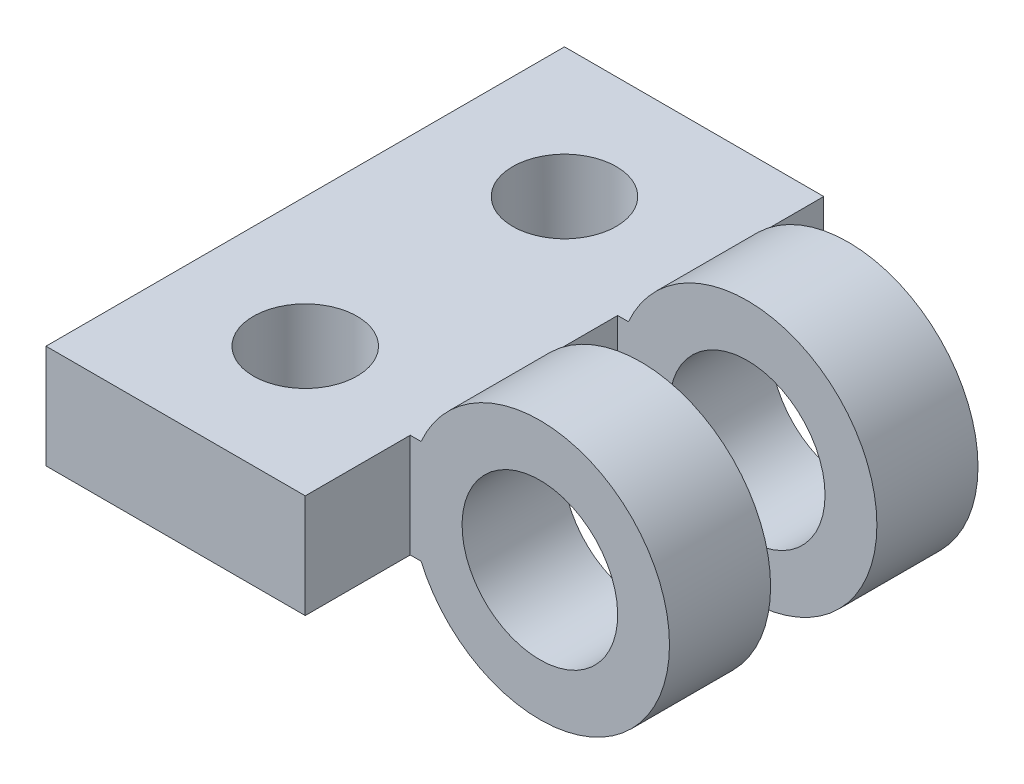
from build123d import *

# Parameters (mm, degrees)
SKETCH2_R                = 2.5
SKETCH2_R_2              = 1.5
BOSS_EXTRUDE1_DEPTH      = 1.95
SKETCH3_W                = 5
SKETCH3_H                = 10
BOSS_EXTRUDE2_DEPTH      = 1
BOSS_EXTRUDE2_DEPTH_BACK = 1
SKETCH5_R                = 2.5
SKETCH5_R_2              = 1.50060411
BOSS_EXTRUDE3_DEPTH      = 0.975
BOSS_EXTRUDE3_DEPTH_BACK = 0.975
SKETCH6_W                = 1.95
SKETCH6_H                = 2
BOSS_EXTRUDE4_DEPTH      = 0.208712
SKETCH7_R                = 1
CUT_EXTRUDE1_DEPTH       = 10


with BuildPart() as part:
    # Sketch2 → Boss-Extrude1 (new body)
    with BuildSketch(Plane.XY):
        Circle(SKETCH2_R)
        Circle(SKETCH2_R_2, mode=Mode.SUBTRACT)
    extrude(amount=BOSS_EXTRUDE1_DEPTH)



with BuildPart() as body_2:
    # Sketch3 → Boss-Extrude2 (new body, two sides)
    with BuildSketch(Plane(origin=(0, 0, 0), x_dir=(1, 0, 0), z_dir=(0, 1, 0))) as boss_extrude2_sk:
        with Locations((-5, -2.975)):
            Rectangle(SKETCH3_W, SKETCH3_H)
    extrude(amount=BOSS_EXTRUDE2_DEPTH)
    extrude(boss_extrude2_sk.sketch, amount=-BOSS_EXTRUDE2_DEPTH_BACK)


with BuildPart() as body_3:
    # Sketch5 → Boss-Extrude3 (new body, two sides)
    with BuildSketch(Plane(origin=(0, 0, 4.975), x_dir=(0, -1, 0), z_dir=(0, 0, 1))) as boss_extrude3_sk:
        Circle(SKETCH5_R)
        Circle(SKETCH5_R_2, mode=Mode.SUBTRACT)
    extrude(amount=BOSS_EXTRUDE3_DEPTH)
    extrude(boss_extrude3_sk.sketch, amount=-BOSS_EXTRUDE3_DEPTH_BACK)


with BuildPart() as part_1:
    add(part.part)

    add(body_2.part)  # Boss-Extrude4 merges body 2

    add(body_3.part)  # Boss-Extrude4 merges body 3
    # Sketch6 → Boss-Extrude4 (add)
    with BuildSketch(Plane(origin=(-2.5, 0, 0), x_dir=(0, 0, -1), z_dir=(1, 0, 0))):
        with Locations((-4.975, 0)):
            Rectangle(SKETCH6_W, SKETCH6_H)
        with Locations((-0.975, 0)):
            Rectangle(SKETCH6_W, SKETCH6_H)
    extrude(amount=BOSS_EXTRUDE4_DEPTH)

    # Sketch7 → Cut-Extrude1 (cut)
    with BuildSketch(Plane(origin=(0, 1, 0), x_dir=(1, 0, 0), z_dir=(0, 1, 0))):
        with Locations((-5, -5.475)):
            Circle(SKETCH7_R)
        with Locations((-5, -0.475)):
            Circle(SKETCH7_R)
    extrude(amount=-CUT_EXTRUDE1_DEPTH, mode=Mode.SUBTRACT)


solid = part_1.part
